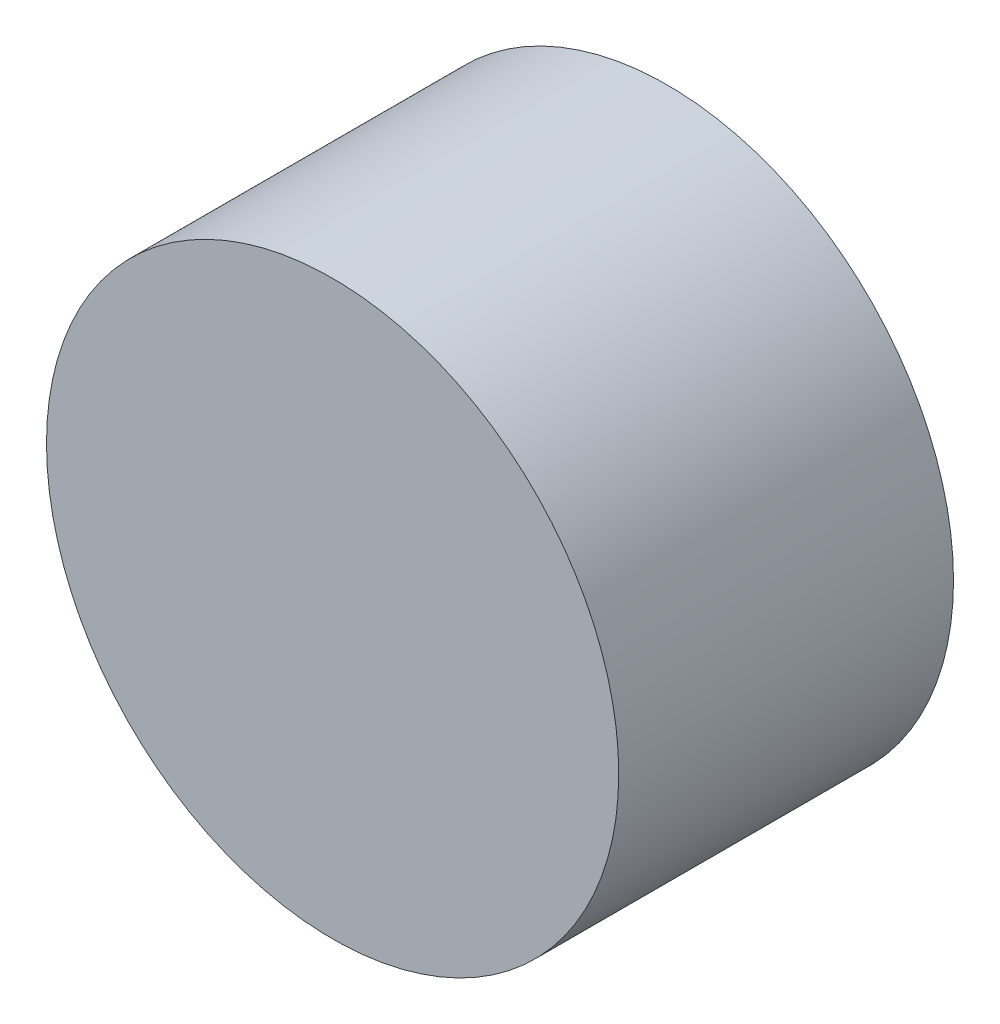
from build123d import *

# Parameters (mm, degrees)
SKETCH1_R      = 20.8407
EXTRUDE1_DEPTH = 24.384


with BuildPart() as part:
    # Sketch1 → Extrude1 (new body)
    with BuildSketch(Plane.XY):
        Circle(SKETCH1_R)
    extrude(amount=EXTRUDE1_DEPTH)


solid = part.part
